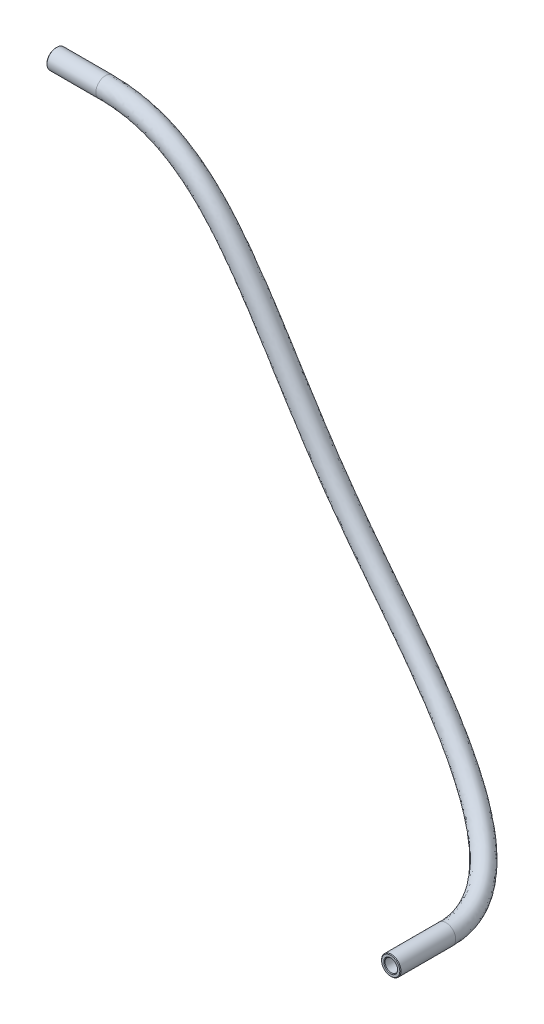
from build123d import *

# Parameters (mm, degrees)
SKETCH3_R     = 2
SKETCH3_R_2   = 1.3
CHAMFER1_SIZE = 0.127


with BuildPart() as part:
    # Sweep1: sweep along a curve in space
    with BuildLine() as sweep1_path:
        Line((201.31049714, -198.353558716, 61.0875), (201.31049714, -198.353558716, 49.6875))
        add(Edge.make_bspline(
            [(201.31049714, -198.353558716, 49.6875), (201.31049714, -198.353558716, 29.196826428), (143.62742272, -152.41790764, 24.856939831), (130.55864243, -106.482256564, 25.525), (107.025, -106.482256564, 25.525)],
            knots=[0, 0, 0, 0, 0.472508915, 1, 1, 1, 1], degree=3))
        Line((96.825, -106.482256564, 25.525), (107.025, -106.482256564, 25.525))
    # Sketch3 → Sweep1 (sweep)
    with BuildSketch(Plane(origin=(104.925, 0, 0), x_dir=(0, 0, -1), z_dir=(1, 0, 0))):
        with Locations((-25.525, -106.482256564)):
            Circle(SKETCH3_R)
        with Locations((-25.525, -106.482256564)):
            Circle(SKETCH3_R_2, mode=Mode.SUBTRACT)
    sweep(path=sweep1_path.line)

    # Chamfer1
    chamfer1_edges = [part.edges().sort_by_distance(p)[0] for p in [
        (96.825, -106.482256564, 26.825),
        (200.344886716, -197.483158515, 61.0875),
        (96.825, -106.482256564, 27.525),
        (199.824942641, -197.014481484, 61.0875),
    ]]
    chamfer(chamfer1_edges, length=CHAMFER1_SIZE)


solid = part.part
